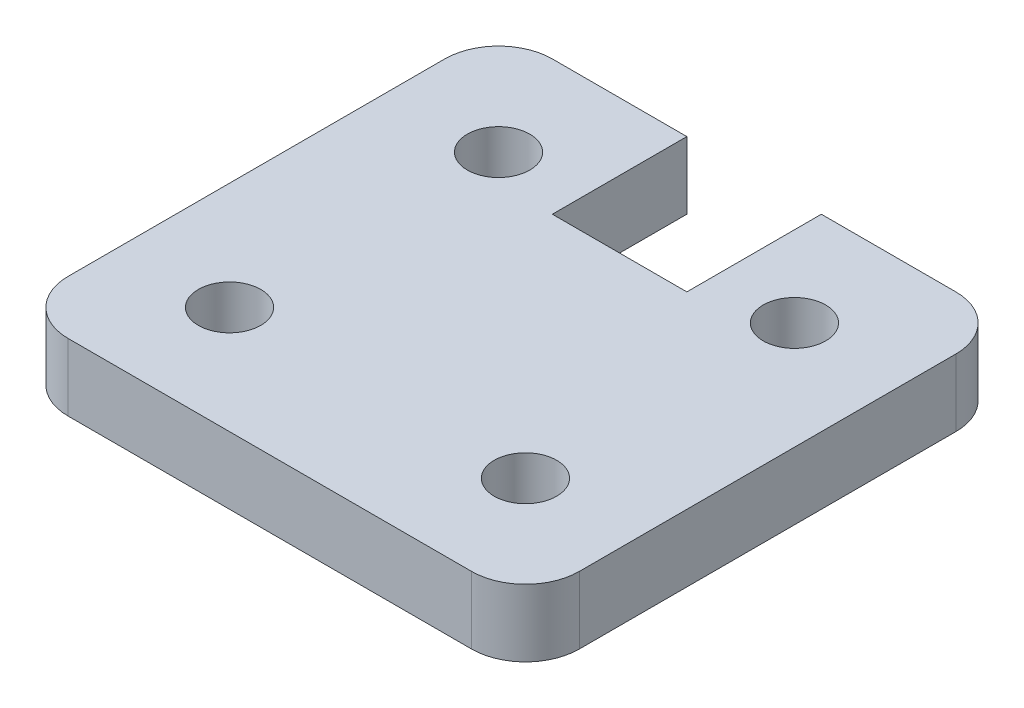
from build123d import *

# Parameters (mm, degrees)
SKETCH1_W           = 24.13
SKETCH1_H           = 22.86
BOSS_EXTRUDE1_DEPTH = 3.175
SKETCH2_R           = 1.4732
CUT_EXTRUDE1_DEPTH  = 4.175
FILLET1_R           = 2.54
SKETCH3_W           = 6.35
SKETCH3_H           = 6.35
CUT_EXTRUDE2_DEPTH  = 4.175


with BuildPart() as part:
    # Sketch1 → Boss-Extrude1 (new body)
    with BuildSketch(Plane(origin=(0, 0, 0), x_dir=(1, 0, 0), z_dir=(0, 1, 0))):
        Rectangle(SKETCH1_W, SKETCH1_H)
    extrude(amount=BOSS_EXTRUDE1_DEPTH)

    # Sketch2 → Cut-Extrude1 (cut, through all)
    with BuildSketch(Plane(origin=(0, 3.175, 0), x_dir=(1, 0, 0), z_dir=(0, 1, 0))):
        with Locations((-6.985, 6.35)):
            Circle(SKETCH2_R)
        with Locations((-6.985, -6.35)):
            Circle(SKETCH2_R)
        with Locations((6.985, -6.35)):
            Circle(SKETCH2_R)
        with Locations((6.985, 6.35)):
            Circle(SKETCH2_R)
    extrude(amount=-CUT_EXTRUDE1_DEPTH, mode=Mode.SUBTRACT)

    # Fillet1
    fillet1_edges = [part.edges().sort_by_distance(p)[0] for p in [
        (12.065, 1.5875, 11.43),
        (-12.065, 1.5875, 11.43),
        (-12.065, 1.5875, -11.43),
        (12.065, 1.5875, -11.43),
    ]]
    fillet(fillet1_edges, radius=FILLET1_R)

    # Sketch3 → Cut-Extrude2 (cut, through all)
    with BuildSketch(Plane(origin=(0, 3.175, 0), x_dir=(1, 0, 0), z_dir=(0, 1, 0))):
        with Locations((0, 8.255)):
            Rectangle(SKETCH3_W, SKETCH3_H)
    extrude(amount=-CUT_EXTRUDE2_DEPTH, mode=Mode.SUBTRACT)


solid = part.part
